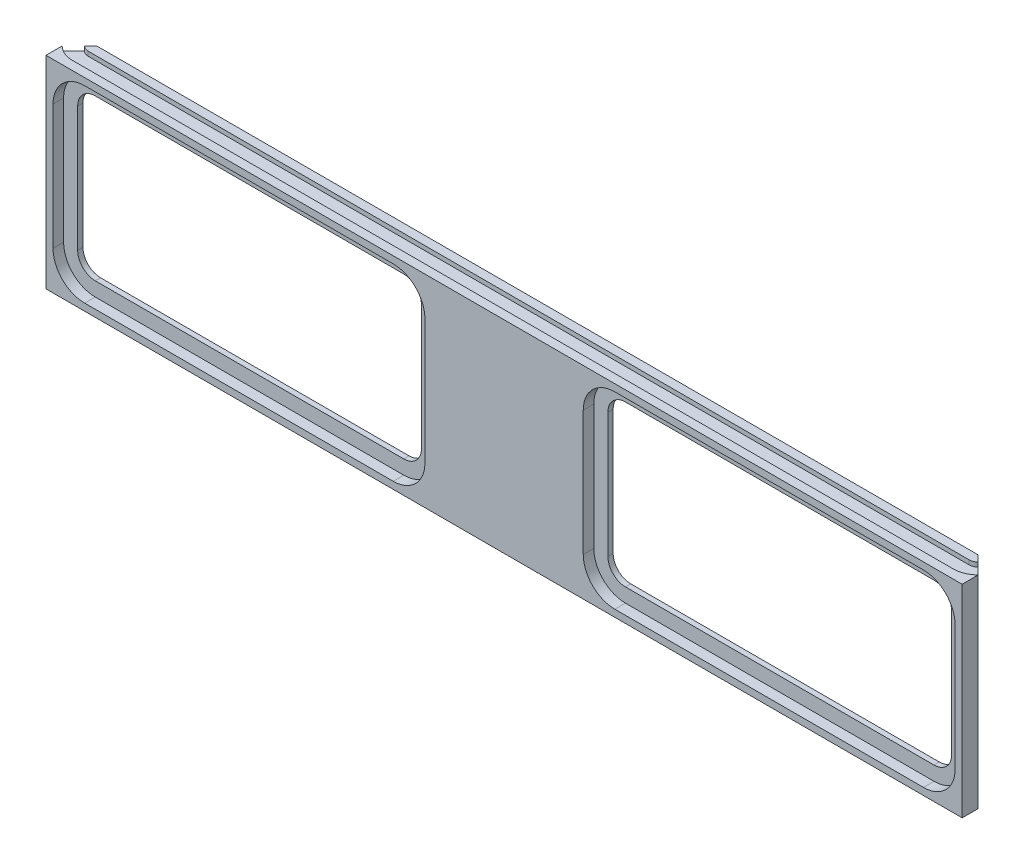
from build123d import *

# Parameters (mm, degrees)
SKETCH1_W           = 520.7
SKETCH1_H           = 115
BOSS_EXTRUDE1_DEPTH = 9
BOSS_EXTRUDE2_DEPTH = 10
CUT_EXTRUDE1_DEPTH  = 9
CUT_EXTRUDE2_DEPTH  = 6
CUT_EXTRUDE3_DEPTH  = 2.5


with BuildPart() as part:
    # Sketch1 → Boss-Extrude1 (new body)
    with BuildSketch(Plane.XY):
        with Locations((0, 42.5)):
            Rectangle(SKETCH1_W, SKETCH1_H)
    extrude(amount=BOSS_EXTRUDE1_DEPTH)

    # Sketch2 → Boss-Extrude2 (add)
    with BuildSketch(Plane(origin=(0, 100, 0), x_dir=(1, 0, 0), z_dir=(0, 1, 0))):
        Polygon((-250.35, 10), (250.35, 10), (260.35, 0), (260.35, -9), (-260.35, -9), (-260.35, 0), align=None)
    extrude(amount=-BOSS_EXTRUDE2_DEPTH)

    # Sketch3 → Cut-Extrude1 (cut)
    with BuildSketch(Plane.XY.offset(9)):
        with BuildLine():
            Line((238.35, 88), (62.991811867, 88))
            ThreePointArc((62.991811867, 88), (55.920744055, 85.071067812), (52.991811867, 78))
            Line((52.991811867, 78), (52.991811867, 7))
            ThreePointArc((52.991811867, 7), (55.920744055, -0.071067812), (62.991811867, -3))
            Line((62.991811867, -3), (238.35, -3))
            ThreePointArc((238.35, -3), (245.421067812, -0.071067812), (248.35, 7))
            Line((248.35, 7), (248.35, 78))
            ThreePointArc((248.35, 78), (245.421067812, 85.071067812), (238.35, 88))
        make_face()
    cut_extrude1 = extrude(amount=-CUT_EXTRUDE1_DEPTH, mode=Mode.SUBTRACT)

    # Sketch4 → Cut-Extrude2 (cut)
    with BuildSketch(Plane.XY.offset(9)):
        with BuildLine():
            Line((62.991811867, -11), (238.35, -11))
            ThreePointArc((238.35, -11), (251.077922061, -5.727922061), (256.35, 7))
            Line((256.35, 7), (256.35, 78))
            ThreePointArc((256.35, 78), (251.077922061, 90.727922061), (238.35, 96))
            Line((238.35, 96), (62.991811867, 96))
            ThreePointArc((62.991811867, 96), (50.263889805, 90.727922061), (44.991811867, 78))
            Line((44.991811867, 78), (44.991811867, 7))
            ThreePointArc((44.991811867, 7), (50.263889805, -5.727922061), (62.991811867, -11))
        make_face()
    cut_extrude2 = extrude(amount=-CUT_EXTRUDE2_DEPTH, mode=Mode.SUBTRACT)

    # Mirror1: Cut-Extrude1, Cut-Extrude2 across plane
    add(cut_extrude1.mirror(Plane(origin=(0, 0, 0), x_dir=(0, 0, 1), z_dir=(1, 0, 0))), mode=Mode.SUBTRACT)
    add(cut_extrude2.mirror(Plane(origin=(0, 0, 0), x_dir=(0, 0, 1), z_dir=(1, 0, 0))), mode=Mode.SUBTRACT)

    # Sketch5 → Cut-Extrude3 (cut)
    with BuildSketch(Plane(origin=(0, 100, 0), x_dir=(1, 0, 0), z_dir=(0, 1, 0))):
        with BuildLine():
            Line((-250.35, 5), (250.35, 5))
            ThreePointArc((250.35, 5), (252.263417162, 5.380602337), (253.885533906, 6.464466094))
            Line((253.885533906, 6.464466094), (260.249494937, 0.100505063))
            ThreePointArc((260.249494937, 0.100505063), (255.707568053, -2.934313455), (250.35, -4))
            Line((250.35, -4), (-250.35, -4))
            ThreePointArc((-250.35, -4), (-255.707568053, -2.934313455), (-260.249494937, 0.100505063))
            Line((-260.249494937, 0.100505063), (-253.885533906, 6.464466094))
            ThreePointArc((-253.885533906, 6.464466094), (-252.263417162, 5.380602337), (-250.35, 5))
        make_face()
    extrude(amount=-CUT_EXTRUDE3_DEPTH, mode=Mode.SUBTRACT)


solid = part.part
